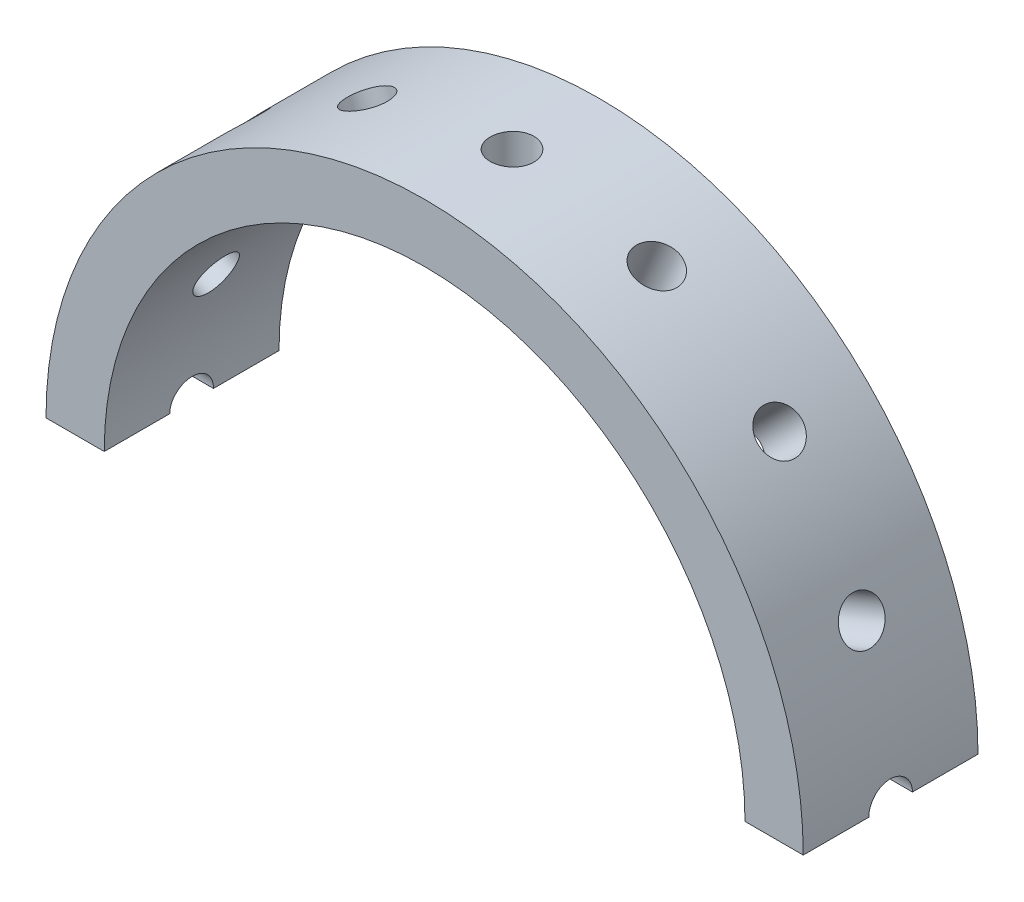
from build123d import *

# Parameters (mm, degrees)
SKETCH_1_R               = 13
SKETCH_1_R_2             = 11
EXTRUDE_1_DEPTH          = 6
SKETCH_2_R               = 0.75
CUT_EXTRUDE_1_DEPTH      = 14
PATTERN_CIRCULAR_1_COUNT = 16
SKETCH_3_W               = 36.79853237
SKETCH_3_H               = 11.94610836
CUT_EXTRUDE_2_DEPTH      = 14.0000001


with BuildPart() as part:
    # ｽｹｯﾁ1 → ﾎﾞｽ - 押し出し1 (new body)
    with BuildSketch(Plane.XY):
        Circle(SKETCH_1_R)
        Circle(SKETCH_1_R_2, mode=Mode.SUBTRACT)
    extrude(amount=EXTRUDE_1_DEPTH)

    # ｽｹｯﾁ2 → ｶｯﾄ - 押し出し1 (cut, through all)
    with BuildSketch(Plane(origin=(0, 0, 0), x_dir=(1, 0, 0), z_dir=(0, 1, 0))):
        with Locations((0, -3)):
            Circle(SKETCH_2_R)
    cut_extrude_1 = extrude(amount=-CUT_EXTRUDE_1_DEPTH, mode=Mode.SUBTRACT)

    # 円形ﾊﾟﾀｰﾝ1: ｶｯﾄ - 押し出し1 ×16 about axis
    pattern_circular_1_axis = Axis((0, 0, 0), (0, 0, 1))
    for i in range(1, PATTERN_CIRCULAR_1_COUNT):
        add(cut_extrude_1.rotate(pattern_circular_1_axis, i * 360 / PATTERN_CIRCULAR_1_COUNT), mode=Mode.SUBTRACT)

    # ｽｹｯﾁ3 → ｶｯﾄ - 押し出し2 (cut, through all)
    with BuildSketch(Plane(origin=(0, 0, 0), x_dir=(1, 0, 0), z_dir=(0, 1, 0))):
        with Locations((0, -2.028241391)):
            Rectangle(SKETCH_3_W, SKETCH_3_H)
    extrude(amount=-CUT_EXTRUDE_2_DEPTH, mode=Mode.SUBTRACT)


solid = part.part
